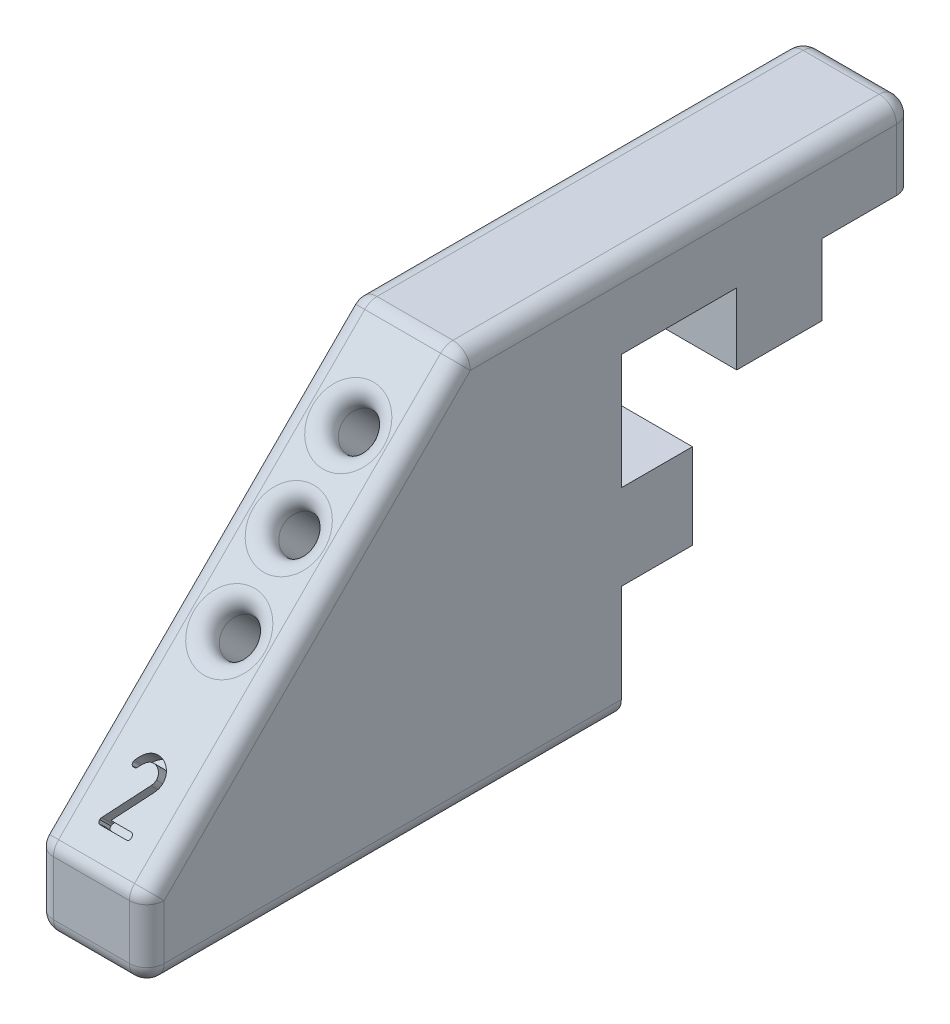
from build123d import *

# Parameters (mm, degrees)
EXTRUDE_1_DEPTH     = 7
SKETCH_2_R          = 1.15
CUT_EXTRUDE_1_DEPTH = 10
SKETCH_5_R          = 1.15
CUT_EXTRUDE_3_DEPTH = 10
FILLET_1_R          = 1.1
CUT_EXTRUDE_4_DEPTH = 1


with BuildPart() as part:
    # Эскиз1 → Бобышка-Вытянуть1 (new body)
    with BuildSketch(Plane.ZY.offset(-220)):
        Polygon((-2.700000149, 10), (-2.700000149, 5.5), (2.700000149, 5.5), (2.700000149, 10), (10.000000149, 10), (10.000000149, 2.700000104), (5.500000149, 2.700000104), (5.500000149, -2.700000194), (10.000000149, -2.700000194), (10.000000149, -10), (40.000000149, -10), (40.000000149, -5), (20.000000149, 15), (-8.500000149, 15), (-8.500000149, 10), align=None)
    extrude(amount=EXTRUDE_1_DEPTH)

    # Эскиз2 → Вырез-Вытянуть1 (cut)
    with BuildSketch(Plane(origin=(0, 17.500000075, 17.500000075), x_dir=(1, 0, 0), z_dir=(0, 0.7071067811865489, 0.7071067811865462))):
        with Locations(Location((216.5, -14.177669635, 0), (0, 0, 270))):
            Circle(SKETCH_2_R)
    extrude(amount=-CUT_EXTRUDE_1_DEPTH, mode=Mode.SUBTRACT)

    # Эскиз5 → Вырез-Вытянуть3 (cut)
    with BuildSketch(Plane(origin=(0, 17.500000075, 17.500000075), x_dir=(1, 0, 0), z_dir=(0, 0.7071067811865489, 0.7071067811865462))):
        with Locations(Location((216.5, -8.856601823, 0), (0, 0, 270))):
            Circle(SKETCH_5_R)
        with Locations(Location((216.5, -19.498737447, 0), (0, 0, 270))):
            Circle(SKETCH_5_R)
    extrude(amount=-CUT_EXTRUDE_3_DEPTH, mode=Mode.SUBTRACT)

    # Скругление1
    fillet_1_edges = [part.edges().sort_by_distance(p)[0] for p in [
        (220, 12.5, -8.500000149),
        (220, 15, 5.75),
        (220, 5, 30.000000149),
        (220, -7.5, 40.000000149),
        (220, -10, 25.000000149),
        (216.5, 15, -8.500000149),
        (216.5, 15, 20.000000149),
        (216.5, -5, 40.000000149),
        (216.5, -10, 40.000000149),
        (213, -10, 25.000000149),
        (216.5, 8.288046533, 26.711953616),
        (213, -7.5, 40.000000149),
        (216.5, 4.5254834, 30.474516749),
        (216.5, 12.050609665, 22.949390484),
        (213, 5, 30.000000149),
        (213, 15, 5.75),
        (213, 12.5, -8.500000149),
    ]]
    fillet(fillet_1_edges, radius=FILLET_1_R)

    # Эскиз6 → Вырез-Вытянуть4 (cut)
    with BuildSketch(Plane(origin=(0, 17.500000075, 17.500000075), x_dir=(1, 0, 0), z_dir=(0, 0.707106781186549, 0.7071067811865462))):
        with BuildLine():
            add(Edge.make_bspline(
                [(216.502435065, -25.86417034), (216.536563033, -25.865221496), (216.60371255, -25.867289731), (216.702509896, -25.880193482), (216.797502694, -25.90299359), (216.888288666, -25.935893054), (216.976029709, -25.976281211), (217.058990215, -26.027141192), (217.138113432, -26.086933249), (217.212888867, -26.154484411), (217.281279441, -26.228230082), (217.341260408, -26.307127858), (217.392409957, -26.389601594), (217.434342901, -26.476295263), (217.465809589, -26.566855017), (217.488759341, -26.661138444), (217.502763598, -26.759314764), (217.50470136, -26.826246251), (217.505681818, -26.860111899)],
                knots=[0, 0, 0, 0, 1.041766559, 2.049759373, 3.035273881, 4.017460812, 4.992853655, 5.978644954, 6.981244037, 8.016212218, 9.050653059, 10.046665791, 11.0367719, 12.008241014, 12.979885633, 13.957373994, 14.966482649, 16, 16, 16, 16], degree=3))
            add(Edge.make_bspline(
                [(217.505681818, -26.860111899), (217.503432714, -26.907658615), (217.498865545, -27.004209893), (217.462636232, -27.14864688), (217.404638062, -27.293498456), (217.350815973, -27.385635252), (217.323051948, -27.433163847)],
                knots=[0, 0, 0, 0, 0.935810177, 1.900313523, 2.916880626, 4, 4, 4, 4], degree=3))
            Line((217.323051948, -27.433163847), (216.058441558, -29.448585925))
            Line((216.058441558, -29.448585925), (217.305194805, -29.448585925))
            add(Edge.make_bspline(
                [(217.305194805, -29.448585925), (217.320952575, -29.449106667), (217.350647274, -29.450087979), (217.392201576, -29.460065459), (217.427876696, -29.475843079), (217.456618488, -29.499740234), (217.478865792, -29.529855517), (217.495475433, -29.566218207), (217.503813047, -29.609475843), (217.505033813, -29.640114546), (217.505681818, -29.656378132)],
                knots=[0, 0, 0, 0, 1.14095523, 2.150070966, 3.080760824, 3.945153579, 4.828279774, 5.776800167, 6.819884637, 8, 8, 8, 8], degree=3))
            add(Edge.make_bspline(
                [(217.505681818, -29.656378132), (217.505033813, -29.672641719), (217.503813047, -29.703280421), (217.495475433, -29.746538058), (217.478865792, -29.782900748), (217.456618488, -29.813016031), (217.427876696, -29.836913185), (217.392201576, -29.852690806), (217.350647274, -29.862668286), (217.320952575, -29.863649598), (217.305194805, -29.86417034)],
                knots=[0, 0, 0, 0, 1.180115363, 2.223199833, 3.171720226, 4.054846421, 4.919239176, 5.849929034, 6.85904477, 8, 8, 8, 8], degree=3))
            Line((217.305194805, -29.86417034), (215.699675325, -29.86417034))
            add(Edge.make_bspline(
                [(215.699675325, -29.86417034), (215.683933164, -29.863567282), (215.65432857, -29.862433176), (215.61274605, -29.853541174), (215.577095512, -29.83854485), (215.548270828, -29.815522562), (215.52624531, -29.786349963), (215.509347256, -29.751498386), (215.501114388, -29.71004685), (215.499853401, -29.680755827), (215.499188312, -29.665306704)],
                knots=[0, 0, 0, 0, 1.166197201, 2.193142131, 3.13613798, 4.007040048, 4.893738447, 5.826868706, 6.853813636, 8, 8, 8, 8], degree=3))
            add(Edge.make_bspline(
                [(215.499188312, -29.665306704), (215.500545826, -29.64516914), (215.503297006, -29.604357748), (215.522659217, -29.568308455), (215.532467532, -29.550046964)],
                knots=[0, 0, 0, 0, 0.986859896, 2, 2, 2, 2], degree=3))
            Line((215.532467532, -29.550046964), (217.004058442, -27.205891119))
            add(Edge.make_bspline(
                [(217.004058442, -27.205891119), (217.019421898, -27.179479546), (217.049535538, -27.127710686), (217.081108754, -27.045100631), (217.100727999, -26.961408789), (217.103386527, -26.905128284), (217.104707792, -26.877157353)],
                knots=[0, 0, 0, 0, 1.051688452, 2.061396058, 3.036530382, 4, 4, 4, 4], degree=3))
            add(Edge.make_bspline(
                [(217.104707792, -26.877157353), (217.104401122, -26.85682656), (217.103796871, -26.816767517), (217.094194077, -26.758125541), (217.080278553, -26.701710753), (217.06225054, -26.647064491), (217.036248612, -26.595477549), (217.005447031, -26.546108342), (216.969585749, -26.498575919), (216.928166943, -26.454376736), (216.883491772, -26.413514712), (216.836140094, -26.377343683), (216.786377846, -26.347059109), (216.733958309, -26.322779543), (216.679476241, -26.302981965), (216.622306603, -26.289304254), (216.563021254, -26.280952172), (216.52275483, -26.280156353), (216.502435065, -26.279754756)],
                knots=[0, 0, 0, 0, 1.033348237, 2.036071235, 3.014398079, 3.989620349, 4.956253624, 5.945657129, 6.947907479, 7.980521803, 9.023273023, 10.025523372, 11.007717137, 11.980799265, 12.960577993, 13.952277545, 14.966651763, 16, 16, 16, 16], degree=3))
            add(Edge.make_bspline(
                [(216.502435065, -26.279754756), (216.474131666, -26.281380338), (216.417101513, -26.284655817), (216.333088605, -26.309743664), (216.250805948, -26.34927274), (216.170745637, -26.405681834), (216.092865656, -26.478006076), (216.016660073, -26.565648709), (215.941528023, -26.668471995), (215.896266541, -26.744704834), (215.872564935, -26.784624886)],
                knots=[0, 0, 0, 0, 0.802989863, 1.617990652, 2.470504536, 3.387253077, 4.388154308, 5.482780424, 6.681833993, 8, 8, 8, 8], degree=3))
            add(Edge.make_bspline(
                [(215.872564935, -26.784624886), (215.86306896, -26.799363595), (215.844430415, -26.828292495), (215.803113907, -26.859883264), (215.753633036, -26.878477726), (215.718243076, -26.880805952), (215.699675325, -26.882027483)],
                knots=[0, 0, 0, 0, 1.002746525, 1.968174689, 2.933979409, 4, 4, 4, 4], degree=3))
            add(Edge.make_bspline(
                [(215.699675325, -26.882027483), (215.683944176, -26.881398221), (215.65436029, -26.880214837), (215.612530112, -26.871627302), (215.577243985, -26.855463651), (215.54856423, -26.832651565), (215.525752144, -26.803971809), (215.509588493, -26.768685682), (215.501000958, -26.726855504), (215.499817573, -26.697271619), (215.499188312, -26.68154047)],
                knots=[0, 0, 0, 0, 1.161746488, 2.184772153, 3.132421671, 4, 4.867578329, 5.815227847, 6.838253512, 8, 8, 8, 8], degree=3))
            add(Edge.make_bspline(
                [(215.499188312, -26.68154047), (215.500057235, -26.667034119), (215.501750412, -26.638767178), (215.512037575, -26.612397121), (215.517045455, -26.599559951)],
                knots=[0, 0, 0, 0, 1.026382828, 2, 2, 2, 2], degree=3))
            add(Edge.make_bspline(
                [(215.517045455, -26.599559951), (215.532691663, -26.569619946), (215.563235107, -26.511173146), (215.613503334, -26.42818001), (215.663857233, -26.349944946), (215.718169501, -26.27854673), (215.772733268, -26.211839023), (215.829908634, -26.151577787), (215.888717549, -26.096804028), (215.949127, -26.047243019), (216.012040101, -26.004133199), (216.076479009, -25.966441952), (216.142887069, -25.934603446), (216.211632658, -25.909733515), (216.281472428, -25.889165211), (216.353357859, -25.874254529), (216.427316836, -25.866457749), (216.477256972, -25.864937033), (216.502435065, -25.86417034)],
                knots=[0, 0, 0, 0, 1.247331567, 2.434954234, 3.582379257, 4.681579802, 5.746075506, 6.763961717, 7.746761029, 8.712805542, 9.646898869, 10.560400761, 11.467760656, 12.362486931, 13.257436386, 14.155004042, 15.069816711, 16, 16, 16, 16], degree=3))
        make_face()
    extrude(amount=-CUT_EXTRUDE_4_DEPTH, mode=Mode.SUBTRACT)


solid = part.part
